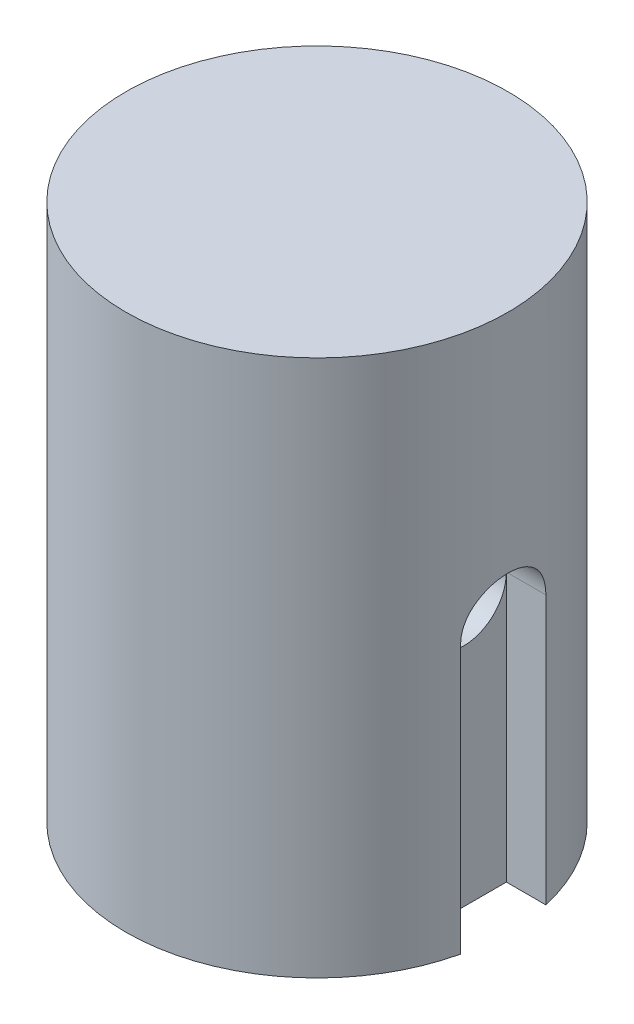
from build123d import *

# Parameters (mm, degrees)
SKETCH1_R               = 8.895
BOSS_EXTRUDE1_DEPTH     = 25
CUT_EXTRUDE1_DEPTH      = 12.5
SKETCH3_R               = 1.984375
CUT_EXTRUDE2_DEPTH      = 9.895
CUT_EXTRUDE2_DEPTH_BACK = 9.895


with BuildPart() as part:
    # Sketch1 → Boss-Extrude1 (new body)
    with BuildSketch(Plane(origin=(0, 0, 0), x_dir=(1, 0, 0), z_dir=(0, 1, 0))):
        Circle(SKETCH1_R)
    extrude(amount=-BOSS_EXTRUDE1_DEPTH)

    # Sketch2 → Cut-Extrude1 (cut)
    with BuildSketch(Plane.XZ.offset(25)):
        with BuildLine():
            Line((-6.83125, 1.984375), (-6.83125, -1.984375))
            Line((-6.83125, -1.984375), (-8.670829306, -1.984375))
            ThreePointArc((-8.670829306, -1.984375), (-8.895, 0), (-8.670829306, 1.984375))
            Line((-8.670829306, 1.984375), (-6.83125, 1.984375))
        make_face()
    cut_extrude1 = extrude(amount=-CUT_EXTRUDE1_DEPTH, mode=Mode.SUBTRACT)

    # Mirror1: Cut-Extrude1 across plane
    add(cut_extrude1.mirror(Plane(origin=(0, 0, 0), x_dir=(0, 0, 1), z_dir=(1, 0, 0))), mode=Mode.SUBTRACT)

    # Sketch3 → Cut-Extrude2 (cut, two sides)
    with BuildSketch(Plane(origin=(0, 0, 0), x_dir=(0, 0, -1), z_dir=(1, 0, 0))) as cut_extrude2_sk:
        with Locations((0, -12.5)):
            Circle(SKETCH3_R)
    extrude(amount=CUT_EXTRUDE2_DEPTH, mode=Mode.SUBTRACT)
    extrude(cut_extrude2_sk.sketch, amount=-CUT_EXTRUDE2_DEPTH_BACK, mode=Mode.SUBTRACT)


solid = part.part
